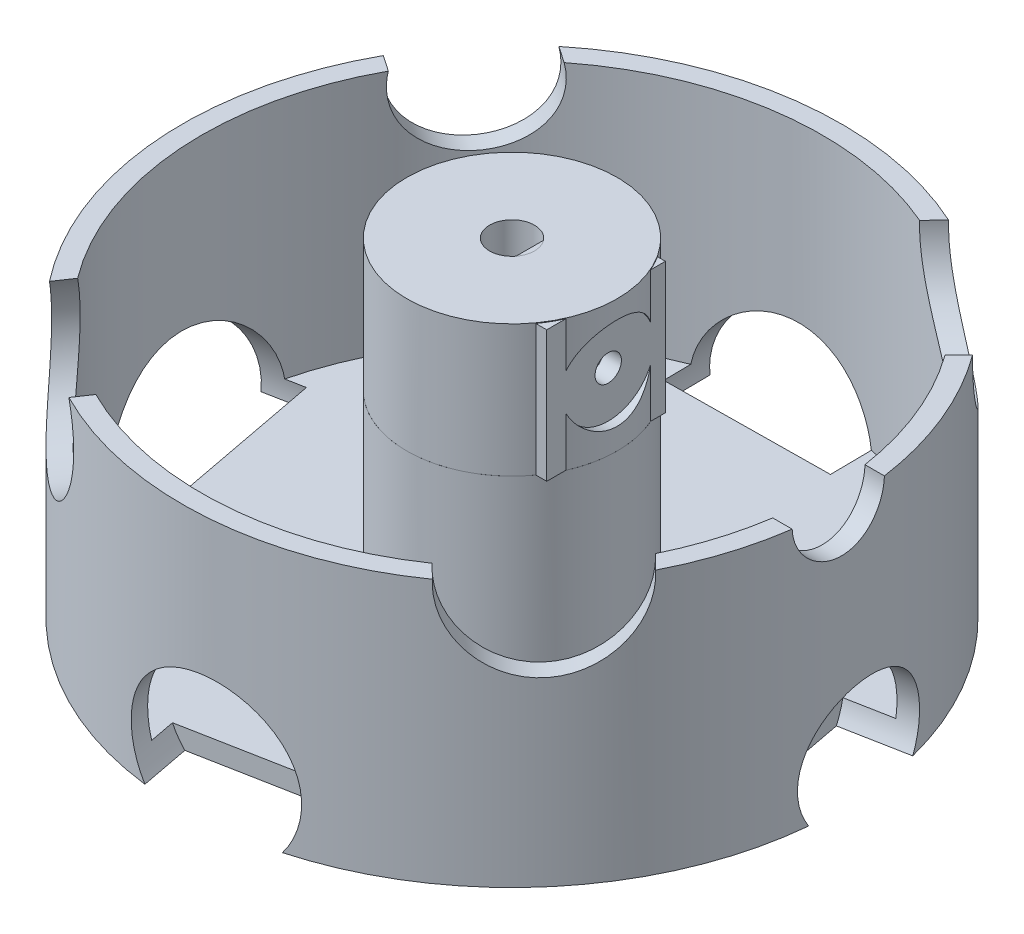
from build123d import *

# Parameters (mm, degrees)
SKETCH1_R               = 15.958
BOSS_EXTRUDE1_DEPTH     = 20
SKETCH2_R               = 3.4
CUT_EXTRUDE1_DEPTH      = 13.55
SKETCH5_W               = 1.550685087
SKETCH5_H               = 7.184215806
BOSS_EXTRUDE2_DEPTH     = 13.55
SKETCH7_W               = 18.003976239
SKETCH7_H               = 19.909960041
BOSS_EXTRUDE3_DEPTH     = 12
SKETCH6_R               = 2
CUT_EXTRUDE2_DEPTH      = 1
CUT_EXTRUDE2_DEPTH_BACK = 13.55
NUTOPENING_DEPTH        = 30
SKETCH10_R              = 50
BOSS_EXTRUDE4_DEPTH     = 30
SKETCH12_R              = 47.082764373
SKETCH12_R_2            = 15.95790089
CUT_EXTRUDE5_DEPTH      = 27
SKETCH13_R              = 50
SKETCH13_R_2            = 47.082764373
BOSS_EXTRUDE5_DEPTH     = 10
CUT_EXTRUDE6_DEPTH      = 6.933086
SKETCH16_R              = 7
CUT_EXTRUDE7_DEPTH      = 40
SKETCH19_R              = 12
CUT_EXTRUDE8_DEPTH      = 10
SKETCH20_R              = 12
CUT_EXTRUDE9_DEPTH      = 10
SKETCH22_R              = 12.553525499
CUT_EXTRUDE10_DEPTH     = 10
SKETCH21_R              = 10
CUT_EXTRUDE11_DEPTH     = 10
SKETCH23_R              = 12.659869084
CUT_EXTRUDE12_DEPTH     = 10
SKETCH25_R              = 9.629681042
CUT_EXTRUDE13_DEPTH     = 10
SKETCH26_R              = 15.012411299
CUT_EXTRUDE14_DEPTH     = 10
SKETCH27_R              = 12.373258501
CUT_EXTRUDE15_DEPTH     = 10


with BuildPart() as part:
    # Sketch1 → Boss-Extrude1 (new body)
    with BuildSketch(Plane(origin=(0, 0, 0), x_dir=(1, 0, 0), z_dir=(0, 1, 0))):
        Circle(SKETCH1_R)
    extrude(amount=BOSS_EXTRUDE1_DEPTH)

    # Sketch2 → Cut-Extrude1 (cut)
    with BuildSketch(Plane(origin=(0, 20, 0), x_dir=(1, 0, 0), z_dir=(0, 1, 0))):
        Circle(SKETCH2_R)
    extrude(amount=-CUT_EXTRUDE1_DEPTH, mode=Mode.SUBTRACT)

    # Sketch5 → Boss-Extrude2 (add)
    with BuildSketch(Plane(origin=(0, 18.26, 0), x_dir=(1, 0, 0), z_dir=(0, 1, 0))):
        with Locations((3.375342544, 0.020519704)):
            Rectangle(SKETCH5_W, SKETCH5_H)
    extrude(amount=-BOSS_EXTRUDE2_DEPTH)

    # Sketch7 → Boss-Extrude3 (add)
    with BuildSketch(Plane.ZY.offset(-2.6)):
        with Locations((0.33027221, 9.954980021)):
            Rectangle(SKETCH7_W, SKETCH7_H)
    extrude(amount=-BOSS_EXTRUDE3_DEPTH)

    # Sketch6 → Cut-Extrude2 (cut, two sides)
    with BuildSketch(Plane.ZY.offset(-2.6)) as cut_extrude2_sk:
        with Locations((0, 10.236925537)):
            Circle(SKETCH6_R)
    extrude(amount=CUT_EXTRUDE2_DEPTH, mode=Mode.SUBTRACT)
    extrude(cut_extrude2_sk.sketch, amount=-CUT_EXTRUDE2_DEPTH_BACK, mode=Mode.SUBTRACT)

    # Sketch9 → NutOpening (cut)
    with BuildSketch(Plane.XY):
        Polygon((11.876516377, 10.236925537), (11.876516377, 5.861925537), (4.943430227, 5.861925537), (4.943430227, 10.236925537), (4.943430227, 14.614332445), (11.876516377, 14.614332445), align=None)
    extrude(amount=-NUTOPENING_DEPTH, mode=Mode.SUBTRACT)

    # Sketch10 → Boss-Extrude4 (add)
    with BuildSketch(Plane.XZ):
        Circle(SKETCH10_R)
    extrude(amount=BOSS_EXTRUDE4_DEPTH)

    # Sketch12 → Cut-Extrude5 (cut)
    with BuildSketch(Plane(origin=(0, 0, 0), x_dir=(1, 0, 0), z_dir=(0, 1, 0))):
        Circle(SKETCH12_R)
        Circle(SKETCH12_R_2, mode=Mode.SUBTRACT)
    extrude(amount=-CUT_EXTRUDE5_DEPTH, mode=Mode.SUBTRACT)

    # Sketch13 → Boss-Extrude5 (add)
    with BuildSketch(Plane(origin=(0, 0, 0), x_dir=(1, 0, 0), z_dir=(0, 1, 0))):
        Circle(SKETCH13_R)
        Circle(SKETCH13_R_2, mode=Mode.SUBTRACT)
    extrude(amount=BOSS_EXTRUDE5_DEPTH)

    # Sketch14 → Cut-Extrude6 (cut)
    with BuildSketch(Plane.ZY.offset(-11.876516377)):
        Polygon((-5.054124256, 10.236925537), (-2.527062128, 5.859925537), (2.527062128, 5.859925537), (5.054124256, 10.236925537), (2.527062128, 14.613925537), (-2.527062128, 14.613925537), align=None)
    extrude(amount=CUT_EXTRUDE6_DEPTH, mode=Mode.SUBTRACT)

    # Sketch16 → Cut-Extrude7 (cut)
    with BuildSketch(Plane(origin=(14.6, 0, 0), x_dir=(0, 0, -1), z_dir=(1, 0, 0))):
        with Locations((0, 10.236925537)):
            Circle(SKETCH16_R)
    extrude(amount=CUT_EXTRUDE7_DEPTH, mode=Mode.SUBTRACT)

    # Sketch19 → Cut-Extrude8 (cut)
    with BuildSketch(Plane(origin=(9.351145186, 0, 49.117777675), x_dir=(0.982355553, 0, -0.187022904), z_dir=(0.187022904, 0, 0.982355553))):
        with Locations((-5.570859196, -22.899801856)):
            Circle(SKETCH19_R)
    extrude(amount=-CUT_EXTRUDE8_DEPTH, mode=Mode.SUBTRACT)

    # Sketch20 → Cut-Extrude9 (cut)
    with BuildSketch(Plane(origin=(35.756785301, 0, 34.949281894), x_dir=(0.698985638, 0, -0.715135706), z_dir=(0.715135706, 0, 0.698985638))):
        with Locations((2.884219354, 9.491522823)):
            Circle(SKETCH20_R)
    extrude(amount=-CUT_EXTRUDE9_DEPTH, mode=Mode.SUBTRACT)

    # Sketch22 → Cut-Extrude10 (cut)
    with BuildSketch(Plane(origin=(34.949281894, 0, -35.756785301), x_dir=(-0.715135706, 0, -0.698985638), z_dir=(0.698985638, 0, -0.715135706))):
        with Locations((4.40106333, 9.339950133)):
            Circle(SKETCH22_R)
    extrude(amount=-CUT_EXTRUDE10_DEPTH, mode=Mode.SUBTRACT)

    # Sketch21 → Cut-Extrude11 (cut)
    with BuildSketch(Plane(origin=(49.117777675, 0, -9.351145186), x_dir=(-0.187022904, 0, -0.982355553), z_dir=(0.982355553, 0, -0.187022904))):
        with Locations((-5.45591263, -24.781077398)):
            Circle(SKETCH21_R)
    extrude(amount=-CUT_EXTRUDE11_DEPTH, mode=Mode.SUBTRACT)

    # Sketch23 → Cut-Extrude12 (cut)
    with BuildSketch(Plane(origin=(-0.570991135, 0, -49.996739585), x_dir=(-0.999934792, 0, 0.011419823), z_dir=(-0.011419823, 0, -0.999934792))):
        with Locations((3.82952566, -28.945993069)):
            Circle(SKETCH23_R)
    extrude(amount=-CUT_EXTRUDE12_DEPTH, mode=Mode.SUBTRACT)

    # Sketch25 → Cut-Extrude13 (cut)
    with BuildSketch(Plane(origin=(-41.343771844, 0, -28.119255498), x_dir=(-0.56238511, 0, 0.826875437), z_dir=(-0.826875437, 0, -0.56238511))):
        with Locations((-4.82858013, 7.970437984)):
            Circle(SKETCH25_R)
    extrude(amount=-CUT_EXTRUDE13_DEPTH, mode=Mode.SUBTRACT)

    # Sketch26 → Cut-Extrude14 (cut)
    with BuildSketch(Plane(origin=(-49.117777675, 0, 9.351145186), x_dir=(0.187022904, 0, 0.982355553), z_dir=(-0.982355553, 0, 0.187022904))):
        with Locations((-4.726082608, -29.099277456)):
            Circle(SKETCH26_R)
    extrude(amount=-CUT_EXTRUDE14_DEPTH, mode=Mode.SUBTRACT)

    # Sketch27 → Cut-Extrude15 (cut)
    with BuildSketch(Plane(origin=(-28.119255498, 0, 41.343771844), x_dir=(0.826875437, 0, 0.56238511), z_dir=(-0.56238511, 0, 0.826875437))):
        with Locations((-4.474622368, 3.952676971)):
            Circle(SKETCH27_R)
    extrude(amount=-CUT_EXTRUDE15_DEPTH, mode=Mode.SUBTRACT)


solid = part.part
